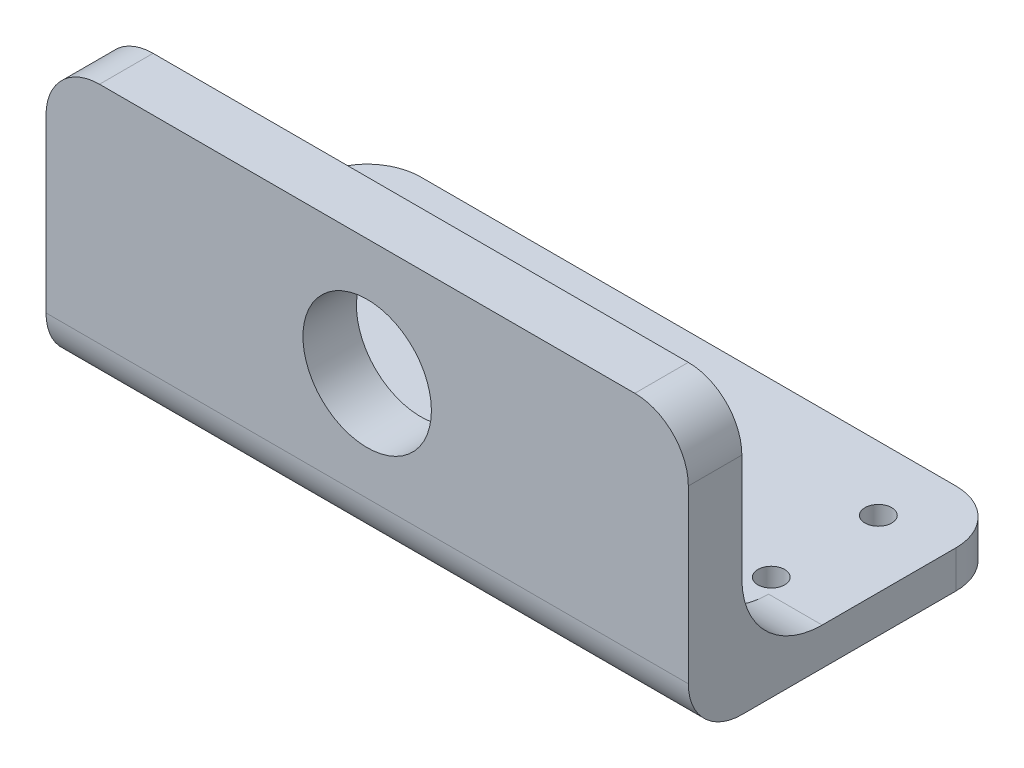
from build123d import *

# Parameters (mm, degrees)
SKETCH_1_W          = 120
SKETCH_1_H          = 60
EXTRUDE_1_DEPTH     = 62
SKETCH_3_W          = 120
SKETCH_3_H          = 50
CUT_EXTRUDE_1_DEPTH = 40
CUT_EXTRUDE_2_DEPTH = 121
CUT_EXTRUDE_3_DEPTH = 50
SKETCH_7_R          = 12
CUT_EXTRUDE_4_DEPTH = 50
SKETCH_8_W          = 120
SKETCH_8_H          = 10
CUT_EXTRUDE_5_DEPTH = 10
FILLET_1_R          = 10
FILLET_2_R          = 10
FILLET_3_R          = 10
SKETCH_9_R          = 2.5
CUT_EXTRUDE_6_DEPTH = 10


with BuildPart() as part:
    # 草图1 → 凸台-拉伸1 (new body)
    with BuildSketch(Plane(origin=(0, -10, 0), x_dir=(1, 0, 0), z_dir=(0, 1, 0))):
        with Locations((0, 32.5)):
            Rectangle(SKETCH_1_W, SKETCH_1_H)
    extrude(amount=-EXTRUDE_1_DEPTH)

    # 草图3 → 切除-拉伸1 (cut)
    with BuildSketch(Plane(origin=(0, -10, 0), x_dir=(1, 0, 0), z_dir=(0, 1, 0))):
        with Locations((0, 37.5)):
            Rectangle(SKETCH_3_W, SKETCH_3_H)
    extrude(amount=-CUT_EXTRUDE_1_DEPTH, mode=Mode.SUBTRACT)

    # 草图4 → 切除-拉伸2 (cut, through all)
    with BuildSketch(Plane(origin=(60, 0, 0), x_dir=(0, 0, -1), z_dir=(1, 0, 0))):
        with BuildLine():
            Line((27.5, -65), (62.5, -65))
            Line((62.5, -65), (62.5, -50))
            Line((62.5, -50), (12.5, -50))
            ThreePointArc((12.5, -50), (16.893398282, -60.606601718), (27.5, -65))
        make_face()
    extrude(amount=-CUT_EXTRUDE_2_DEPTH, mode=Mode.SUBTRACT)

    # 草图6 → 切除-拉伸3 (cut, symmetric)
    with BuildSketch(Plane(origin=(0, 0, 0), x_dir=(0, 0, -1), z_dir=(1, 0, 0))):
        Polygon((12.5, -50), (12.5, -65), (27.5, -65), align=None)
    extrude(amount=CUT_EXTRUDE_3_DEPTH, both=True, mode=Mode.SUBTRACT)

    # 草图7 → 切除-拉伸4 (cut, symmetric)
    with BuildSketch(Plane(origin=(0, 0, -12.5), x_dir=(-1, 0, 0), z_dir=(0, 0, -1))):
        with Locations((0, -41.8)):
            Circle(SKETCH_7_R)
    extrude(amount=CUT_EXTRUDE_4_DEPTH, both=True, mode=Mode.SUBTRACT)

    # 草图8 → 切除-拉伸5 (cut)
    with BuildSketch(Plane(origin=(0, -10, 0), x_dir=(1, 0, 0), z_dir=(0, 1, 0))):
        with Locations((0, 7.5)):
            Rectangle(SKETCH_8_W, SKETCH_8_H)
    extrude(amount=-CUT_EXTRUDE_5_DEPTH, mode=Mode.SUBTRACT)

    # 圆角1
    fillet_1_edges = [part.edges().sort_by_distance(p)[0] for p in [
        (60, -20, -7.5),
        (-60, -20, -7.5),
    ]]
    fillet(fillet_1_edges, radius=FILLET_1_R)

    # 圆角2
    fillet_2_edges = [part.edges().sort_by_distance(p)[0] for p in [
        (-60, -68.5, -62.5),
        (60, -68.5, -62.5),
    ]]
    fillet(fillet_2_edges, radius=FILLET_2_R)

    # 圆角3
    fillet_3_edges = [part.edges().sort_by_distance(p)[0] for p in [
        (0, -72, -2.5),
    ]]
    fillet(fillet_3_edges, radius=FILLET_3_R)

    # 草图9 → 切除-拉伸6 (cut)
    with BuildSketch(Plane(origin=(0, -65, 0), x_dir=(1, 0, 0), z_dir=(0, 1, 0))):
        with Locations((47.5, 50.5)):
            Circle(SKETCH_9_R)
        with Locations((47.5, 30.5)):
            Circle(SKETCH_9_R)
        with Locations((-47.5, 50.5)):
            Circle(SKETCH_9_R)
        with Locations((-47.5, 30.5)):
            Circle(SKETCH_9_R)
    extrude(amount=-CUT_EXTRUDE_6_DEPTH, mode=Mode.SUBTRACT)


solid = part.part
